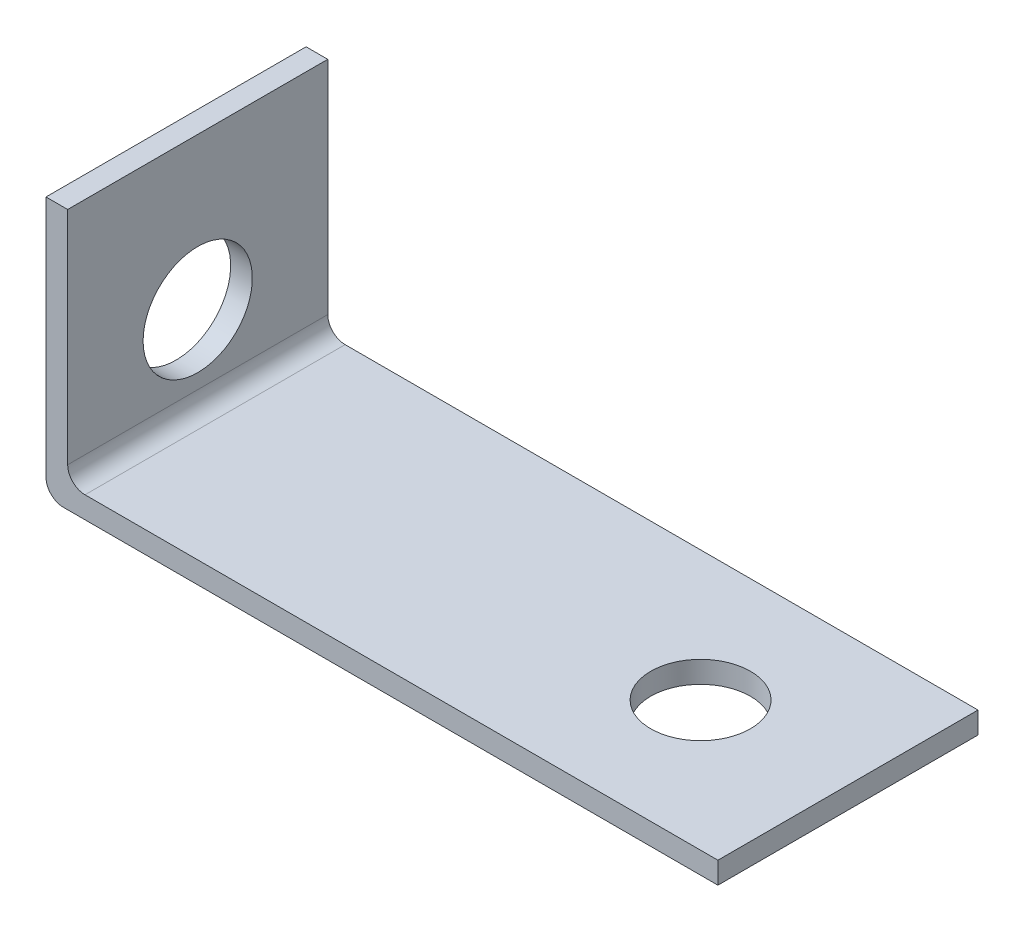
from build123d import *

# Parameters (mm, degrees)
SKETCH1_W           = 95.25
SKETCH1_H           = 38.1
BOSS_EXTRUDE1_DEPTH = 3.175
SKETCH2_W           = 38.1
SKETCH2_H           = 38.1
BOSS_EXTRUDE2_DEPTH = 3.175
SKETCH3_R           = 7.3025
CUT_EXTRUDE2_DEPTH  = 39.1
SKETCH4_R           = 8.001
CUT_EXTRUDE3_DEPTH  = 4.175
FILLET1_R           = 2.54


with BuildPart() as part:
    # Sketch1 → Boss-Extrude1 (new body)
    with BuildSketch(Plane(origin=(0, 0, 0), x_dir=(1, 0, 0), z_dir=(0, 1, 0))):
        Rectangle(SKETCH1_W, SKETCH1_H)
    extrude(amount=BOSS_EXTRUDE1_DEPTH)

    # Sketch2 → Boss-Extrude2 (add)
    with BuildSketch(Plane.ZY.offset(47.625)):
        with Locations((0, 19.05)):
            Rectangle(SKETCH2_W, SKETCH2_H)
    extrude(amount=BOSS_EXTRUDE2_DEPTH)

    # Sketch3 → Cut-Extrude2 (cut, through all)
    with BuildSketch(Plane(origin=(0, 0, 0), x_dir=(1, 0, 0), z_dir=(0, 1, 0))):
        with Locations((26.035, 0)):
            Circle(SKETCH3_R)
    extrude(amount=CUT_EXTRUDE2_DEPTH, mode=Mode.SUBTRACT)

    # Sketch4 → Cut-Extrude3 (cut, through all)
    with BuildSketch(Plane.ZY.offset(47.625)):
        with Locations((0, 15.875)):
            Circle(SKETCH4_R)
    extrude(amount=CUT_EXTRUDE3_DEPTH, mode=Mode.SUBTRACT)

    # Fillet1
    fillet1_edges = [part.edges().sort_by_distance(p)[0] for p in [
        (-47.625, 3.175, 0),
        (-50.8, 0, 0),
    ]]
    fillet(fillet1_edges, radius=FILLET1_R)


solid = part.part
